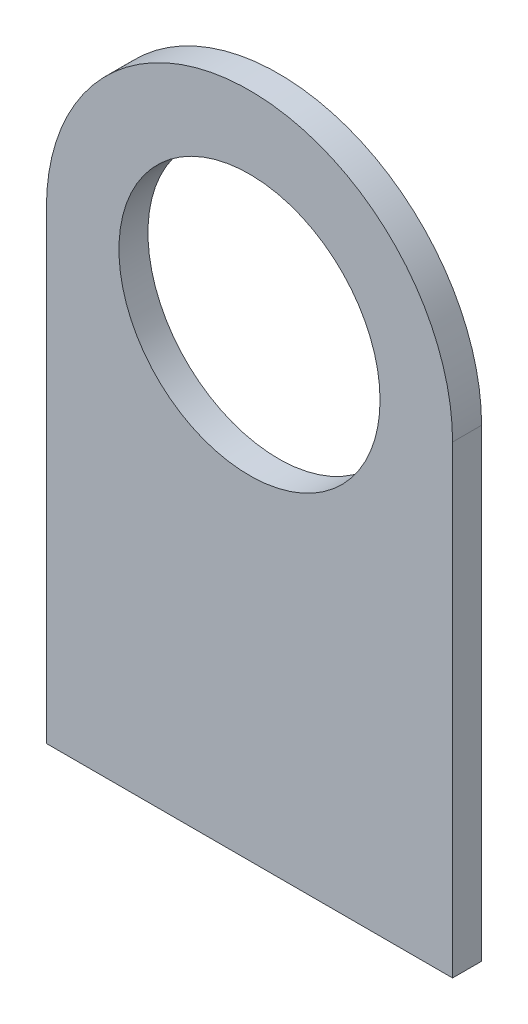
from build123d import *

# Parameters (mm, degrees)
SKETCH1_R           = 14.2875
BOSS_EXTRUDE1_DEPTH = 3.175


with BuildPart() as part:
    # Sketch1 → Boss-Extrude1 (new body)
    with BuildSketch(Plane.XY):
        with BuildLine():
            Line((-22.225, 0), (-22.225, -50.8))
            Line((-22.225, -50.8), (22.225, -50.8))
            Line((22.225, -50.8), (22.225, 0))
            ThreePointArc((22.225, 0), (0, 22.225), (-22.225, 0))
        make_face()
        Circle(SKETCH1_R, mode=Mode.SUBTRACT)
    extrude(amount=BOSS_EXTRUDE1_DEPTH)


solid = part.part
